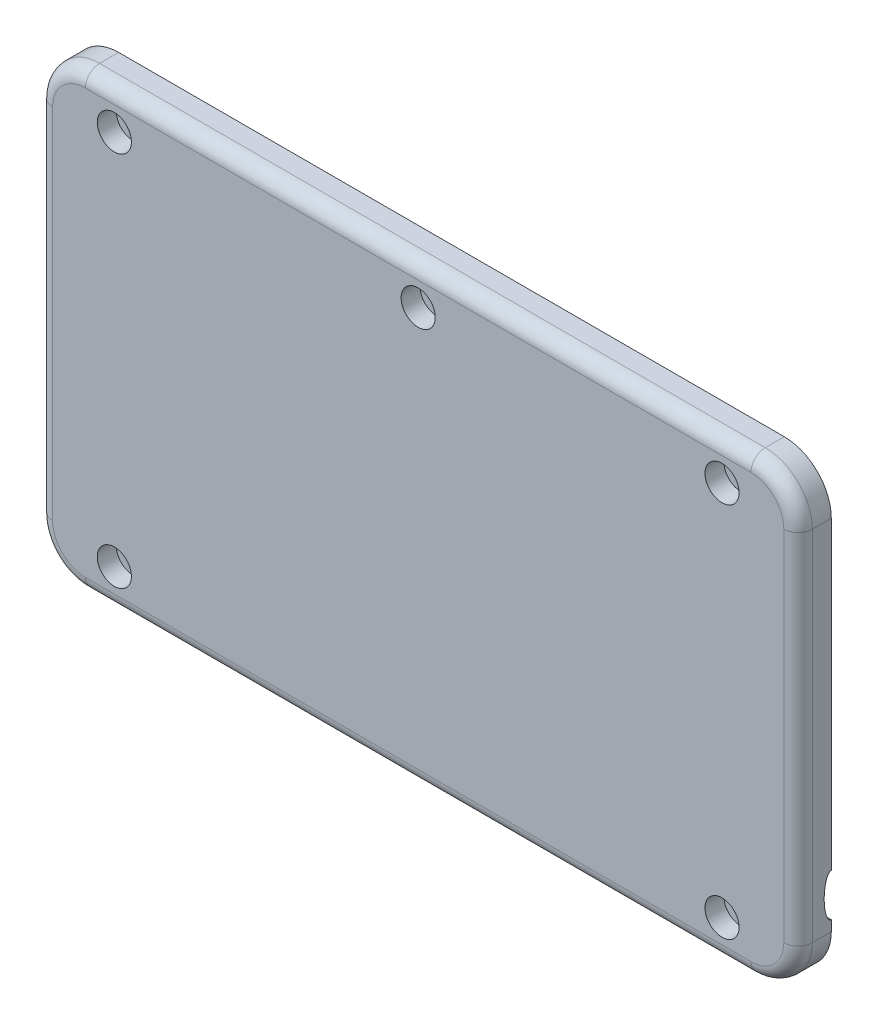
from build123d import *

# Parameters (mm, degrees)
BOSS_EXTRUDE1_DEPTH                             = 8.89
FILLET1_R                                       = 3.81
SHELL1_T                                        = -2.54
BOSS_EXTRUDE4_REACH                             = 10.89
BOSS_EXTRUDE2_REACH                             = 10.763
SKETCH3_R                                       = 3.5052
BOSS_EXTRUDE3_DEPTH                             = 1.5875
CBORE_FOR_8_PAN_HEAD_MACHINE_SCREW1_D           = 4.9149
CBORE_FOR_8_PAN_HEAD_MACHINE_SCREW1_CBORE_D     = 9.12876
CBORE_FOR_8_PAN_HEAD_MACHINE_SCREW1_CBORE_DEPTH = 5.08
CUT_EXTRUDE1_REACH                              = 205.12
CUT_EXTRUDE3_REACH                              = 205.12
CUT_EXTRUDE4_REACH                              = 205.12


with BuildPart() as part:
    # Sketch1 → Boss-Extrude1 (new body)
    with BuildSketch(Plane.XY):
        with BuildLine():
            Line((5.08, 103.26), (5.08, 21.725))
            Line((5.08, 21.725), (5.08, 7.5))
            ThreePointArc((5.08, 7.5), (1.395403307, -1.395403307), (-7.5, -5.08))
            Line((-7.5, -5.08), (-185.46, -5.08))
            ThreePointArc((-185.46, -5.08), (-194.355403307, -1.395403307), (-198.04, 7.5))
            Line((-198.04, 7.5), (-198.04, 103.26))
            ThreePointArc((-198.04, 103.26), (-194.355403307, 112.155403307), (-185.46, 115.84))
            Line((-185.46, 115.84), (-7.5, 115.84))
            ThreePointArc((-7.5, 115.84), (1.395403307, 112.155403307), (5.08, 103.26))
        make_face()
    extrude(amount=BOSS_EXTRUDE1_DEPTH)

    # Fillet1
    fillet1_edges = [part.edges().sort_by_distance(p)[0] for p in [
        (-96.48, -5.08, 8.89),
        (1.395403307, -1.395403307, 8.89),
        (5.08, 55.38, 8.89),
        (1.395403307, 112.155403307, 8.89),
        (-96.48, 115.84, 8.89),
        (-194.355403307, 112.155403307, 8.89),
        (-198.04, 55.38, 8.89),
        (-194.355403307, -1.395403307, 8.89),
    ]]
    fillet(fillet1_edges, radius=FILLET1_R)

    # Shell1
    shell1_openings = [part.faces().sort_by_distance(p)[0] for p in [
        (-96.48, 55.38, 0),
    ]]
    offset(amount=SHELL1_T, openings=shell1_openings, kind=Kind.INTERSECTION)

    # Sketch7 → Boss-Extrude4 (add, up to next)
    with BuildSketch(Plane(origin=(0, 0, 0), x_dir=(-1, 0, 0), z_dir=(0, 0, -1)), mode=Mode.PRIVATE) as boss_extrude4_sk1:
        with BuildLine():
            Line((-2.54, 7.5), (-2.54, 103.26))
            ThreePointArc((-2.54, 103.26), (-1.17755726, 108.30991089), (2.54, 111.989261137))
            Line((2.54, 111.989261137), (2.54, 95.52))
            Line((2.54, 95.52), (2.54, 92.98))
            Line((2.54, 92.98), (2.54, 21.725))
            Line((2.54, 21.725), (2.54, 10.295))
            Line((2.54, 10.295), (2.54, -1.229261137))
            ThreePointArc((2.54, -1.229261137), (-1.17755726, 2.45008911), (-2.54, 7.5))
        make_face()
    boss_extrude4_tool1 = extrude(boss_extrude4_sk1.sketch, amount=-BOSS_EXTRUDE4_REACH, mode=Mode.PRIVATE) - part.part
    add(boss_extrude4_tool1.solids().sort_by_distance((-0.052284, 55.38, 0))[0])

    # Sketch2 → Boss-Extrude2 (add, up to next)
    with BuildSketch(Plane(origin=(0, 0, 0.127), x_dir=(-1, 0, 0), z_dir=(0, 0, -1)), mode=Mode.PRIVATE) as boss_extrude2_sk1:
        with BuildLine():
            Line((13.97, 110.59868885), (13.97, 113.3))
            Line((13.97, 113.3), (16.51, 113.3))
            Line((16.51, 113.3), (16.51, 110.59868885))
            ThreePointArc((16.51, 110.59868885), (15.24, 100.6), (13.97, 110.59868885))
        make_face()
    boss_extrude2_tool1 = extrude(boss_extrude2_sk1.sketch, amount=-BOSS_EXTRUDE2_REACH, mode=Mode.PRIVATE) - part.part
    add(boss_extrude2_tool1.solids().sort_by_distance((-15.24, 106.155134, 0.127))[0])
    # Sketch2 → Boss-Extrude2 (add, up to next)
    with BuildSketch(Plane(origin=(0, 0, 0.127), x_dir=(-1, 0, 0), z_dir=(0, 0, -1)), mode=Mode.PRIVATE) as boss_extrude2_sk2:
        with BuildLine():
            Line((95.21, 110.59868885), (95.21, 113.3))
            Line((95.21, 113.3), (97.75, 113.3))
            Line((97.75, 113.3), (97.75, 110.59868885))
            ThreePointArc((97.75, 110.59868885), (96.48, 100.6), (95.21, 110.59868885))
        make_face()
    boss_extrude2_tool2 = extrude(boss_extrude2_sk2.sketch, amount=-BOSS_EXTRUDE2_REACH, mode=Mode.PRIVATE) - part.part
    add(boss_extrude2_tool2.solids().sort_by_distance((-96.48, 106.155134, 0.127))[0])
    # Sketch2 → Boss-Extrude2 (add, up to next)
    with BuildSketch(Plane(origin=(0, 0, 0.127), x_dir=(-1, 0, 0), z_dir=(0, 0, -1)), mode=Mode.PRIVATE) as boss_extrude2_sk3:
        with BuildLine():
            Line((176.45, 110.59868885), (176.45, 113.3))
            Line((176.45, 113.3), (178.99, 113.3))
            Line((178.99, 113.3), (178.99, 110.59868885))
            ThreePointArc((178.99, 110.59868885), (177.72, 100.6), (176.45, 110.59868885))
        make_face()
    boss_extrude2_tool3 = extrude(boss_extrude2_sk3.sketch, amount=-BOSS_EXTRUDE2_REACH, mode=Mode.PRIVATE) - part.part
    add(boss_extrude2_tool3.solids().sort_by_distance((-177.72, 106.155134, 0.127))[0])
    # Sketch2 → Boss-Extrude2 (add, up to next)
    with BuildSketch(Plane(origin=(0, 0, 0.127), x_dir=(-1, 0, 0), z_dir=(0, 0, -1)), mode=Mode.PRIVATE) as boss_extrude2_sk4:
        with BuildLine():
            Line((176.45, -2.54), (176.45, 0.16131115))
            ThreePointArc((176.45, 0.16131115), (177.72, 10.16), (178.99, 0.16131115))
            Line((178.99, 0.16131115), (178.99, -2.54))
            Line((178.99, -2.54), (176.45, -2.54))
        make_face()
    boss_extrude2_tool4 = extrude(boss_extrude2_sk4.sketch, amount=-BOSS_EXTRUDE2_REACH, mode=Mode.PRIVATE) - part.part
    add(boss_extrude2_tool4.solids().sort_by_distance((-177.72, 4.604866, 0.127))[0])
    # Sketch2 → Boss-Extrude2 (add, up to next)
    with BuildSketch(Plane(origin=(0, 0, 0.127), x_dir=(-1, 0, 0), z_dir=(0, 0, -1)), mode=Mode.PRIVATE) as boss_extrude2_sk5:
        with BuildLine():
            Line((13.97, -2.54), (13.97, 0.16131115))
            ThreePointArc((13.97, 0.16131115), (15.24, 10.16), (16.51, 0.16131115))
            Line((16.51, 0.16131115), (16.51, -2.54))
            Line((16.51, -2.54), (13.97, -2.54))
        make_face()
    boss_extrude2_tool5 = extrude(boss_extrude2_sk5.sketch, amount=-BOSS_EXTRUDE2_REACH, mode=Mode.PRIVATE) - part.part
    add(boss_extrude2_tool5.solids().sort_by_distance((-15.24, 4.604866, 0.127))[0])

    # Sketch3 → Boss-Extrude3 (add)
    with BuildSketch(Plane(origin=(0, 0, 0.127), x_dir=(-1, 0, 0), z_dir=(0, 0, -1))):
        with Locations((15.24, 105.68)):
            Circle(SKETCH3_R)
        with Locations((96.48, 105.68)):
            Circle(SKETCH3_R)
        with Locations((177.72, 105.68)):
            Circle(SKETCH3_R)
        with Locations((177.72, 5.08)):
            Circle(SKETCH3_R)
        with Locations((15.24, 5.08)):
            Circle(SKETCH3_R)
    extrude(amount=BOSS_EXTRUDE3_DEPTH)

    # CBORE for #8 Pan Head Machine Screw1 (through all)
    with Locations(Plane(origin=(-15.24, 5.08, 8.89), x_dir=(0, 1, 0), z_dir=(0, 0, 1))):
        with Locations((0, 0), (0, 162.48), (100.6, 162.48), (100.6, 81.24), (100.6, 0)):
            CounterBoreHole(CBORE_FOR_8_PAN_HEAD_MACHINE_SCREW1_D / 2, CBORE_FOR_8_PAN_HEAD_MACHINE_SCREW1_CBORE_D / 2, CBORE_FOR_8_PAN_HEAD_MACHINE_SCREW1_CBORE_DEPTH)

    # Sketch5 → Cut-Extrude1 (cut, up to next)
    with BuildSketch(Plane(origin=(-198.04, 192.96, 0), x_dir=(0, 1, 0), z_dir=(1, 0, 0)), mode=Mode.PRIVATE) as cut_extrude1_sk1:
        with BuildLine():
            Line((-171.235, 0), (-182.665, 0))
            add(Edge.make_bspline(
                [(-171.235, 0), (-171.235, 1.905), (-176.95, 1.905), (-182.665, 1.905), (-182.665, 0)],
                knots=[3.141592654, 3.141592654, 3.141592654, 4.71238898, 4.71238898, 6.283185307, 6.283185307, 6.283185307], degree=2, weights=[1, 0.707106781, 1, 0.707106781, 1]))
        make_face()
    cut_extrude1_tool1 = extrude(cut_extrude1_sk1.sketch, amount=CUT_EXTRUDE1_REACH, mode=Mode.PRIVATE) & part.part
    add(cut_extrude1_tool1.solids().sort_by_distance((-198.04, 16.01, 0.808344))[0], mode=Mode.SUBTRACT)

    # Sketch6 → Cut-Extrude3 (cut, up to next)
    with BuildSketch(Plane(origin=(5.08, -160.94, 0), x_dir=(0, -1, 0), z_dir=(-1, 0, 0)), mode=Mode.PRIVATE) as cut_extrude3_sk1:
        with BuildLine():
            Line((-171.235, 0), (-182.665, 0))
            add(Edge.make_bspline(
                [(-171.235, 0), (-171.235, 1.905), (-176.95, 1.905), (-182.665, 1.905), (-182.665, 0)],
                knots=[3.141592654, 3.141592654, 3.141592654, 4.71238898, 4.71238898, 6.283185307, 6.283185307, 6.283185307], degree=2, weights=[1, 0.707106781, 1, 0.707106781, 1]))
        make_face()
    cut_extrude3_tool1 = extrude(cut_extrude3_sk1.sketch, amount=CUT_EXTRUDE3_REACH, mode=Mode.PRIVATE) & part.part
    add(cut_extrude3_tool1.solids().sort_by_distance((5.08, 16.01, 0.808344))[0], mode=Mode.SUBTRACT)

    # Sketch8 → Cut-Extrude4 (cut, up to next)
    with BuildSketch(Plane(origin=(-198.04, -139.35, 0), x_dir=(0, -1, 0), z_dir=(-1, 0, 0)), mode=Mode.PRIVATE) as cut_extrude4_sk1:
        with BuildLine():
            Line((-171.235, 0), (-182.665, 0))
            add(Edge.make_bspline(
                [(-171.235, 0), (-171.235, 1.905), (-176.95, 1.905), (-182.665, 1.905), (-182.665, 0)],
                knots=[3.141592654, 3.141592654, 3.141592654, 4.71238898, 4.71238898, 6.283185307, 6.283185307, 6.283185307], degree=2, weights=[1, 0.707106781, 1, 0.707106781, 1]))
        make_face()
    cut_extrude4_tool1 = extrude(cut_extrude4_sk1.sketch, amount=-CUT_EXTRUDE4_REACH, mode=Mode.PRIVATE) & part.part
    add(cut_extrude4_tool1.solids().sort_by_distance((-198.04, 37.6, 0.808344))[0], mode=Mode.SUBTRACT)


solid = part.part
